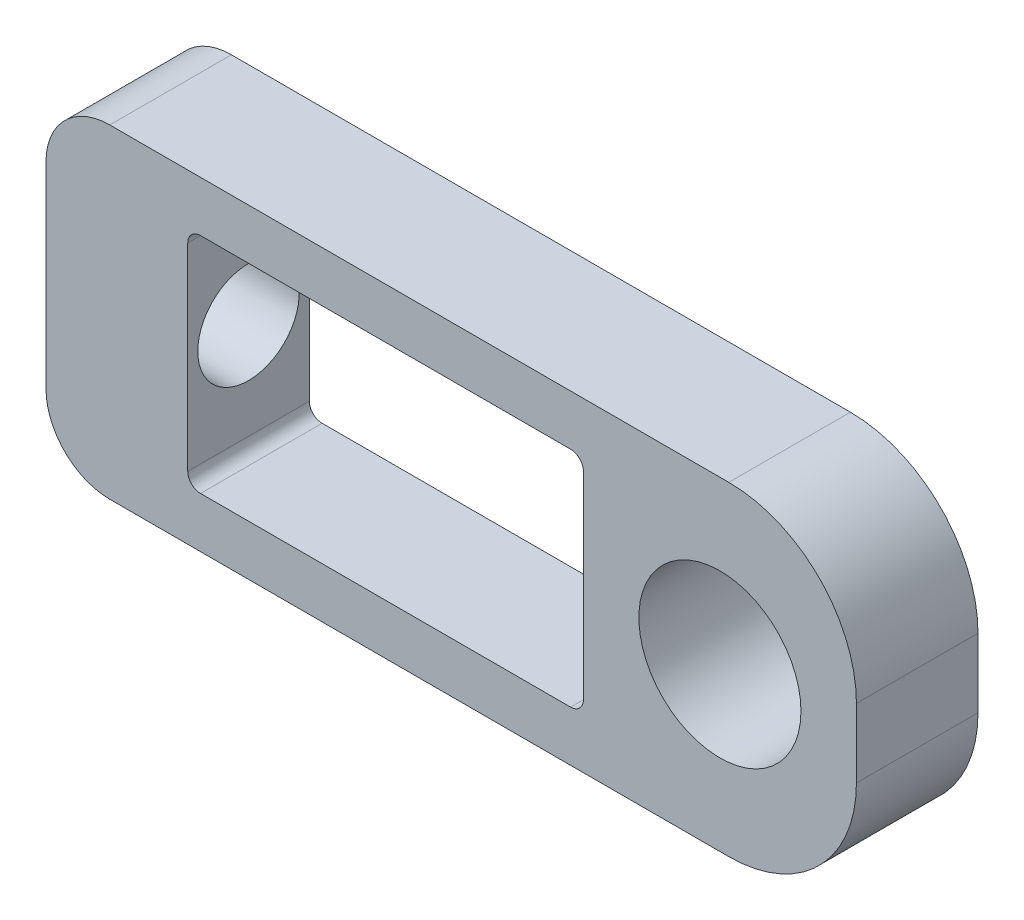
from build123d import *

# Parameters (mm, degrees)
SKETCH1_W           = 63.5
SKETCH1_H           = 25.4
BOSS_EXTRUDE1_DEPTH = 9.525
SKETCH5_R           = 6.35
SKETCH5_W           = 31
SKETCH5_H           = 17.5
CUT_EXTRUDE3_DEPTH  = 10.525
CUT_EXTRUDE2_REACH  = 65.5
SKETCH4_R           = 3.9751
FILLET4_R           = 10
FILLET5_R           = 5
FILLET6_R           = 1


with BuildPart() as part:
    # Sketch1 → Boss-Extrude1 (new body)
    with BuildSketch(Plane.XY):
        with Locations((31.75, 12.7)):
            Rectangle(SKETCH1_W, SKETCH1_H)
    extrude(amount=BOSS_EXTRUDE1_DEPTH)

    # Sketch5 → Cut-Extrude3 (cut, through all)
    with BuildSketch(Plane.XY.offset(9.525)):
        with Locations((52.803125, 12.7)):
            Circle(SKETCH5_R)
        with Locations((26.60625, 12.7)):
            Rectangle(SKETCH5_W, SKETCH5_H)
    extrude(amount=-CUT_EXTRUDE3_DEPTH, mode=Mode.SUBTRACT)

    # Sketch4 → Cut-Extrude2 (cut, up to next)
    with BuildSketch(Plane.ZY, mode=Mode.PRIVATE) as cut_extrude2_sk1:
        with Locations((4.7625, 12.7)):
            Circle(SKETCH4_R)
    cut_extrude2_tool1 = extrude(cut_extrude2_sk1.sketch, amount=-CUT_EXTRUDE2_REACH, mode=Mode.PRIVATE) & part.part
    add(cut_extrude2_tool1.solids().sort_by_distance((0, 12.7, 4.7625))[0], mode=Mode.SUBTRACT)

    # Fillet4
    fillet4_edges = [part.edges().sort_by_distance(p)[0] for p in [
        (63.5, 25.4, 4.7625),
        (63.5, 0, 4.7625),
    ]]
    fillet(fillet4_edges, radius=FILLET4_R)

    # Fillet5
    fillet5_edges = [part.edges().sort_by_distance(p)[0] for p in [
        (0, 25.4, 4.7625),
        (0, 0, 4.7625),
    ]]
    fillet(fillet5_edges, radius=FILLET5_R)

    # Fillet6
    fillet6_edges = [part.edges().sort_by_distance(p)[0] for p in [
        (42.10625, 21.45, 4.7625),
        (42.10625, 3.95, 4.7625),
        (11.10625, 3.95, 4.7625),
        (11.10625, 21.45, 4.7625),
    ]]
    fillet(fillet6_edges, radius=FILLET6_R)


solid = part.part
